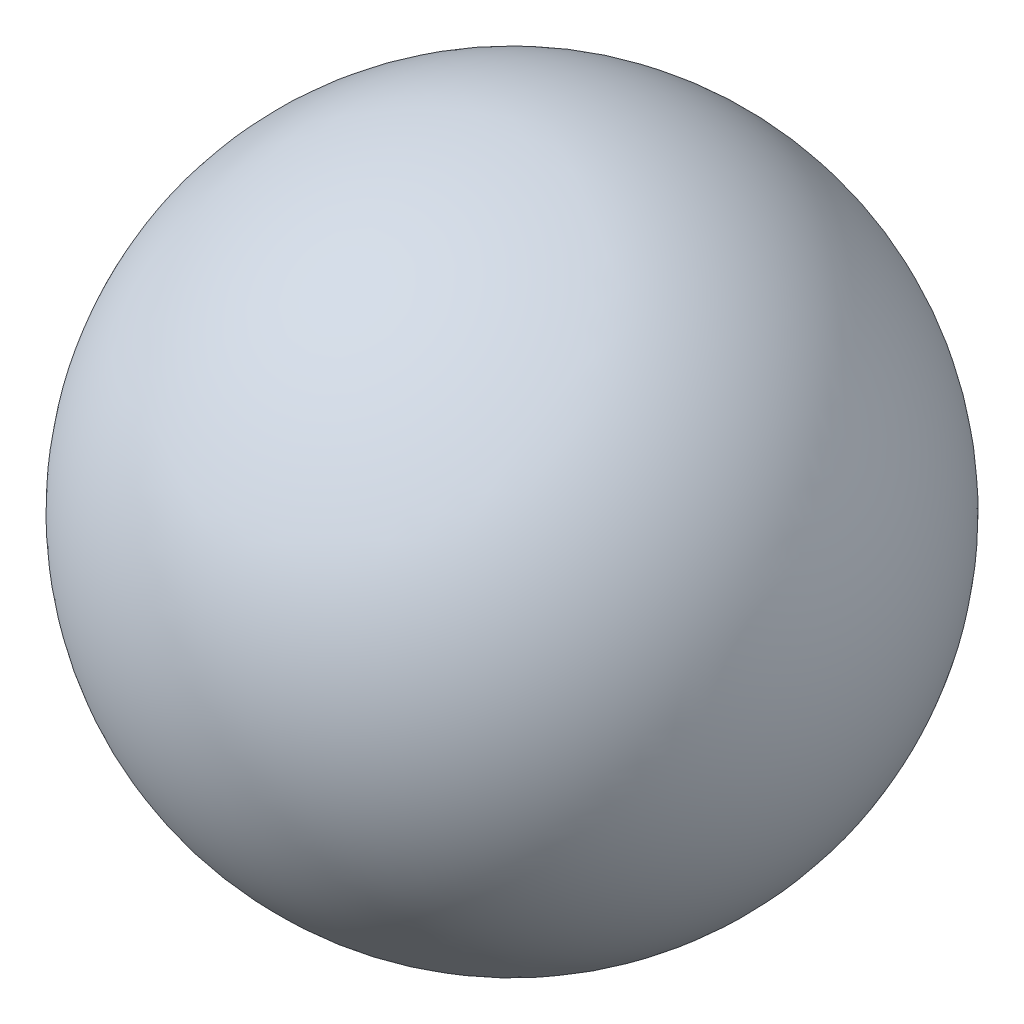
from build123d import *


with BuildPart() as part:
    # Çizim1 one side → Döndür3 (revolve)
    with BuildSketch(Plane(origin=(0, 0, 0), x_dir=(1, 0, 0), z_dir=(0, 1, 0))):
        with BuildLine():
            Line((-7.5, 0), (7.5, 0))
            ThreePointArc((7.5, 0), (0, 7.5), (-7.5, 0))
        make_face()
    revolve(axis=Axis((-8.25, 0, 0), (1, 0, 0)))


solid = part.part
